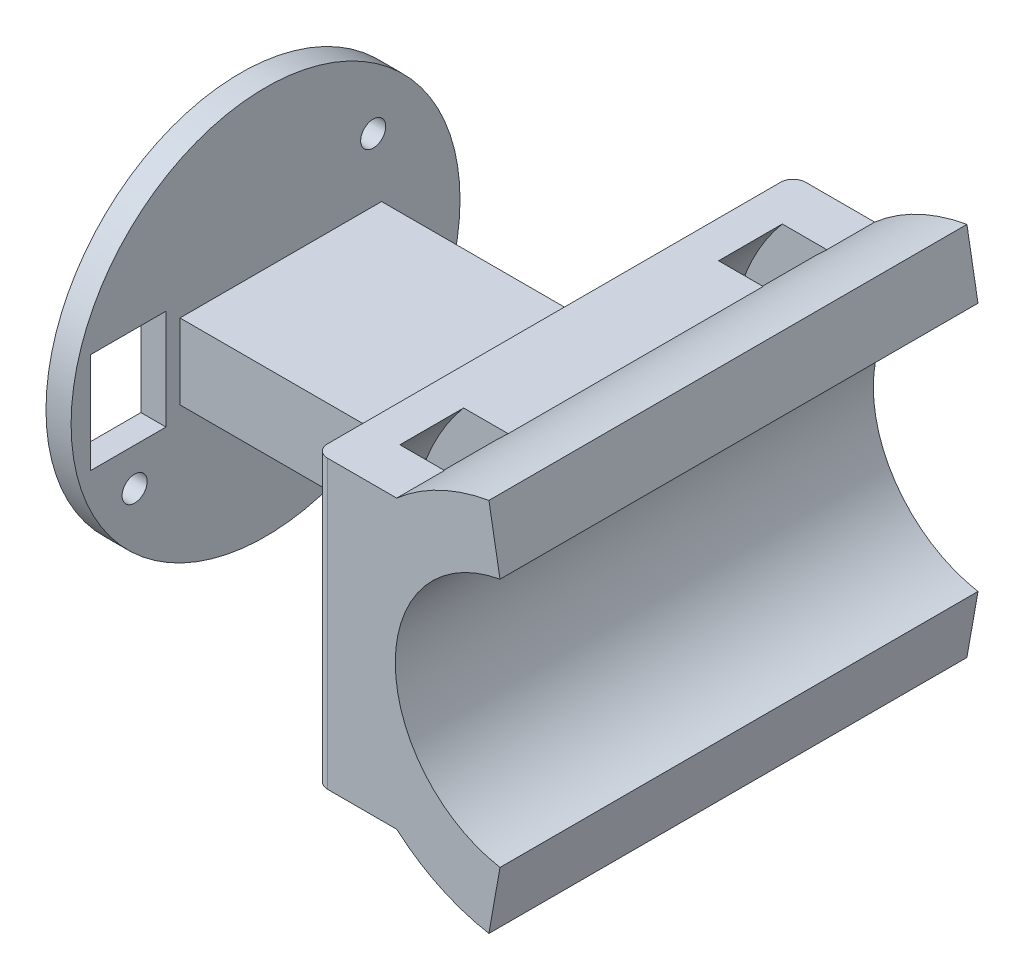
from build123d import *

# Parameters (mm, degrees)
BOSS_EXTRUDE1_DEPTH = 19.05
SKETCH6_W           = 16.071399664
SKETCH6_H           = 6
BOSS_EXTRUDE3_DEPTH = 23
SKETCH3_W           = 2.54
SKETCH3_H           = 5.08
SKETCH4_R           = 15.5
SKETCH4_R_2         = 1
SKETCH4_W           = 8
SKETCH4_H           = 6
BOSS_EXTRUDE2_DEPTH = 2
FILLET1_R           = 1


with BuildPart() as part:
    # Sketch1 → Boss-Extrude1 (new, symmetric)
    with BuildSketch(Plane.XY):
        with BuildLine():
            Line((8.346153406, -9.946558305), (7.464020663, -14.949381691))
            ThreePointArc((7.464020663, -14.949381691), (3.546652059, -13.692553844), (0.110630651, -11.43))
            Line((0.110630651, -11.43), (-6.389369349, -11.43))
            Line((-6.389369349, -11.43), (-6.389369349, 11.43))
            Line((-6.389369349, 11.43), (0.110630651, 11.43))
            ThreePointArc((0.110630651, 11.43), (3.546652059, 13.692553844), (7.464020663, 14.949381691))
            Line((7.464020663, 14.949381691), (8.346153406, 9.946558305))
            ThreePointArc((8.346153406, 9.946558305), (0, 0), (8.346153406, -9.946558305))
        make_face()
    extrude(amount=BOSS_EXTRUDE1_DEPTH, both=True)

    # Sketch6 → Boss-Extrude3 (add)
    with BuildSketch(Plane.ZY.offset(6.389369349)):
        with Locations((-1.213689559, 0)):
            Rectangle(SKETCH6_W, SKETCH6_H)
    extrude(amount=BOSS_EXTRUDE3_DEPTH)

    # Sketch3 → Cut-Revolve1 (revolve, cut)
    with BuildSketch(Plane(origin=(0, 0, 0), x_dir=(1, 0, 0), z_dir=(0, 1, 0))):
        with Locations((-6.35, 12.7)):
            Rectangle(SKETCH3_W, SKETCH3_H)
        with Locations((-6.35, -12.7)):
            Rectangle(SKETCH3_W, SKETCH3_H)
    revolve(axis=Axis((10.1, 0, 19.05), (0, 0, -1)), mode=Mode.SUBTRACT)

    # Sketch4 → Boss-Extrude2 (add)
    with BuildSketch(Plane(origin=(-29.389369349, 0, 0), x_dir=(0, -1, 0), z_dir=(-1, 0, 0))):
        Circle(SKETCH4_R)
        with Locations((6.97426488, 10.435972737)):
            Circle(SKETCH4_R_2, mode=Mode.SUBTRACT)
        with Locations((-8.02573512, -8.580948715)):
            Circle(SKETCH4_R_2, mode=Mode.SUBTRACT)
        with Locations((-0.025715642, 10.93618237)):
            Rectangle(SKETCH4_W, SKETCH4_H, mode=Mode.SUBTRACT)
    extrude(amount=BOSS_EXTRUDE2_DEPTH)

    # Fillet1
    fillet1_edges = [part.edges().sort_by_distance(p)[0] for p in [
        (-6.389369349, 0, -19.05),
        (-6.389369349, 0, 19.05),
    ]]
    fillet(fillet1_edges, radius=FILLET1_R)


solid = part.part
